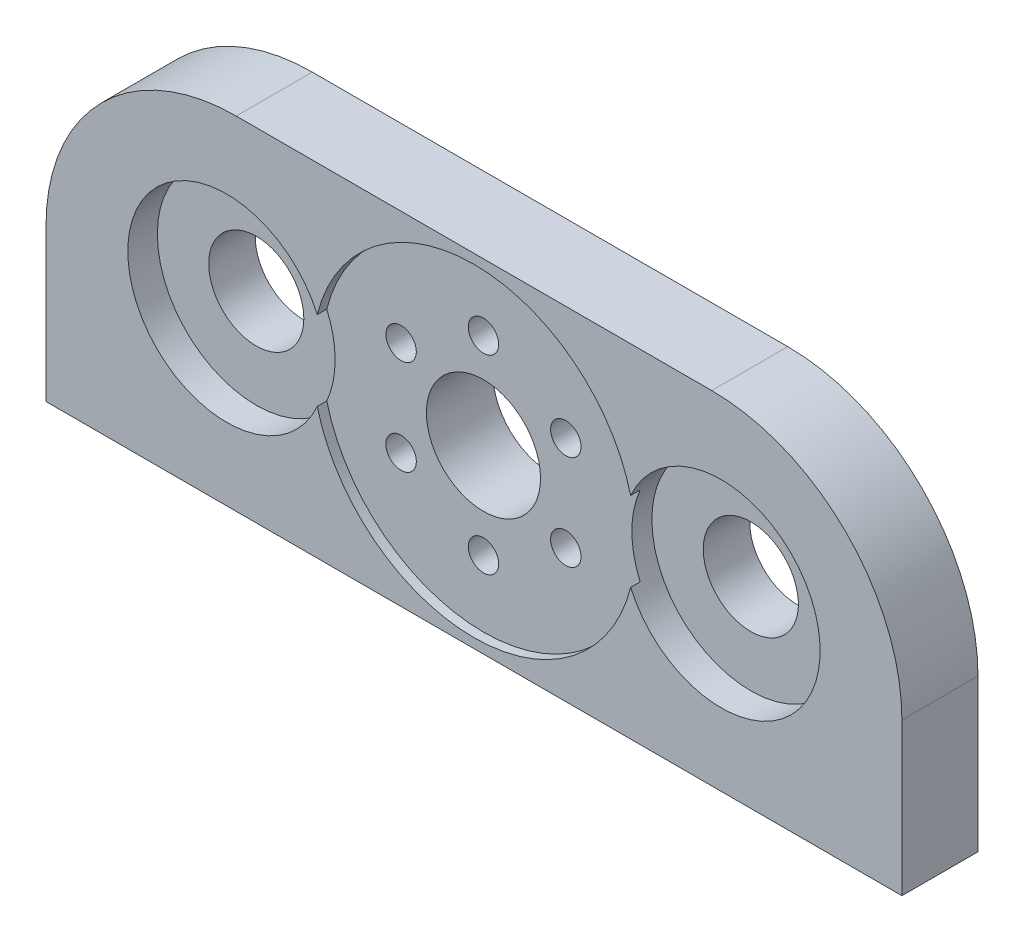
from build123d import *

# Parameters (mm, degrees)
SKETCH1_W           = 45
SKETCH1_H           = 4
BOSS_EXTRUDE1_DEPTH = 18
SKETCH2_R           = 8.5
CUT_EXTRUDE2_DEPTH  = 0.5
SKETCH3_R           = 3
CUT_EXTRUDE3_DEPTH  = 4.5
SKETCH4_R           = 2.5
CUT_EXTRUDE4_DEPTH  = 5
SKETCH6_R           = 0.8
CUT_EXTRUDE6_DEPTH  = 4.5
FILLET1_R           = 10
SKETCH7_R           = 5.2
CUT_EXTRUDE7_DEPTH  = 1.555


with BuildPart() as part:
    # Sketch1 → Boss-Extrude1 (new body)
    with BuildSketch(Plane(origin=(0, 0, 0), x_dir=(1, 0, 0), z_dir=(0, 1, 0))):
        with Locations((-22.5, 2)):
            Rectangle(SKETCH1_W, SKETCH1_H)
    extrude(amount=BOSS_EXTRUDE1_DEPTH)

    # Sketch2 → Cut-Extrude2 (cut)
    with BuildSketch(Plane.XY):
        with Locations((-22.5, 9)):
            Circle(SKETCH2_R)
    extrude(amount=-CUT_EXTRUDE2_DEPTH, mode=Mode.SUBTRACT)

    # Sketch3 → Cut-Extrude3 (cut, through all)
    with BuildSketch(Plane.XY.offset(-0.5)):
        with Locations((-22.5, 9)):
            Circle(SKETCH3_R)
    extrude(amount=-CUT_EXTRUDE3_DEPTH, mode=Mode.SUBTRACT)

    # Sketch4 → Cut-Extrude4 (cut, through all)
    with BuildSketch(Plane.XY):
        with Locations((-35.5, 9)):
            Circle(SKETCH4_R)
        with Locations((-9.5, 9)):
            Circle(SKETCH4_R)
    extrude(amount=-CUT_EXTRUDE4_DEPTH, mode=Mode.SUBTRACT)

    # Sketch6 → Cut-Extrude6 (cut, through all)
    with BuildSketch(Plane.XY.offset(-0.5)):
        with Locations((-22.5, 14)):
            Circle(SKETCH6_R)
        with Locations((-18.169872981, 11.5)):
            Circle(SKETCH6_R)
        with Locations((-18.169872981, 6.5)):
            Circle(SKETCH6_R)
        with Locations((-22.5, 4)):
            Circle(SKETCH6_R)
        with Locations((-26.830127019, 6.5)):
            Circle(SKETCH6_R)
        with Locations((-26.830127019, 11.5)):
            Circle(SKETCH6_R)
    extrude(amount=-CUT_EXTRUDE6_DEPTH, mode=Mode.SUBTRACT)

    # Fillet1
    fillet1_edges = [part.edges().sort_by_distance(p)[0] for p in [
        (-45, 18, -2),
        (0, 18, -2),
    ]]
    fillet(fillet1_edges, radius=FILLET1_R)

    # Sketch7 → Cut-Extrude7 (cut)
    with BuildSketch(Plane.XY):
        with Locations((-35.5, 9)):
            Circle(SKETCH7_R)
        with Locations((-9.5, 9)):
            Circle(SKETCH7_R)
    extrude(amount=-CUT_EXTRUDE7_DEPTH, mode=Mode.SUBTRACT)


solid = part.part
